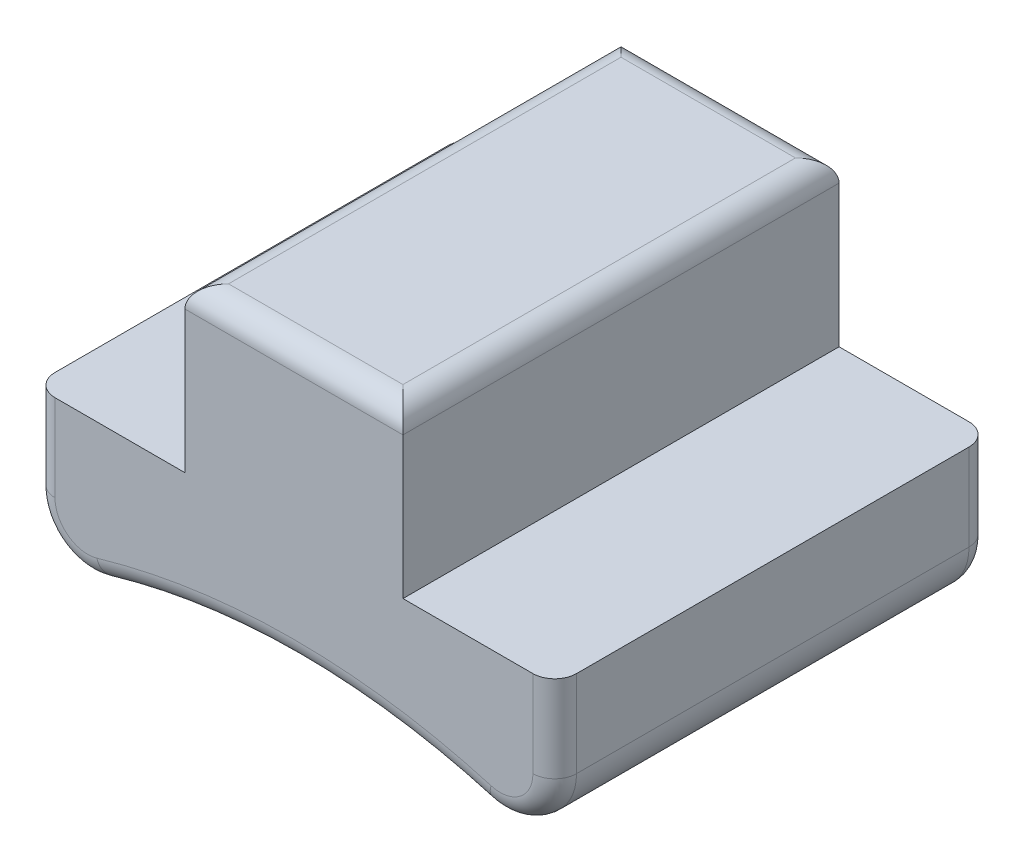
from build123d import *

# Parameters (mm, degrees)
BOSS_EXTRUDE1_DEPTH = 50.8
FILLET1_R           = 6.35
FILLET3_R           = 2.54
FILLET4_R           = 2.54
FILLET5_R           = 2.54


with BuildPart() as part:
    # Sketch1 → Boss-Extrude1 (new body)
    with BuildSketch(Plane.XY):
        with BuildLine():
            Line((-12.7, 111.432937893), (12.7, 111.432937893))
            Line((12.7, 111.432937893), (12.7, 92.382937893))
            Line((12.7, 92.382937893), (30.375497444, 92.382937893))
            Line((30.375497444, 92.382937893), (30.375497444, 73.332937893))
            ThreePointArc((30.375497444, 73.332937893), (0, 79.375), (-30.375497444, 73.332937893))
            Line((-30.375497444, 73.332937893), (-30.375497444, 92.382937893))
            Line((-30.375497444, 92.382937893), (-12.7, 92.382937893))
            Line((-12.7, 92.382937893), (-12.7, 111.432937893))
        make_face()
    extrude(amount=BOSS_EXTRUDE1_DEPTH)

    # Fillet1
    fillet1_edges = [part.edges().sort_by_distance(p)[0] for p in [
        (30.375497444, 73.332937893, 25.4),
        (-30.375497444, 73.332937893, 25.4),
    ]]
    fillet(fillet1_edges, radius=FILLET1_R)

    # Fillet3
    fillet3_edges = [part.edges().sort_by_distance(p)[0] for p in [
        (-12.7, 111.432937893, 25.4),
        (12.7, 111.432937893, 25.4),
        (0, 111.432937893, 50.8),
        (0, 111.432937893, 0),
    ]]
    fillet(fillet3_edges, radius=FILLET3_R)

    # Fillet4
    fillet4_edges = [part.edges().sort_by_distance(p)[0] for p in [
        (0, 79.375, 50.8),
        (30.375497444, 87.336186401, 50.8),
        (27.834803015, 77.208914161, 50.8),
        (-27.834803015, 77.208914161, 50.8),
        (-30.375497444, 87.336186401, 50.8),
    ]]
    fillet(fillet4_edges, radius=FILLET4_R)

    # Fillet5
    fillet5_edges = [part.edges().sort_by_distance(p)[0] for p in [
        (-30.375497444, 87.336186401, 0),
        (0, 79.375, 0),
        (30.375497444, 87.336186401, 0),
        (27.834803015, 77.208914161, 0),
        (-27.834803015, 77.208914161, 0),
    ]]
    fillet(fillet5_edges, radius=FILLET5_R)


solid = part.part
